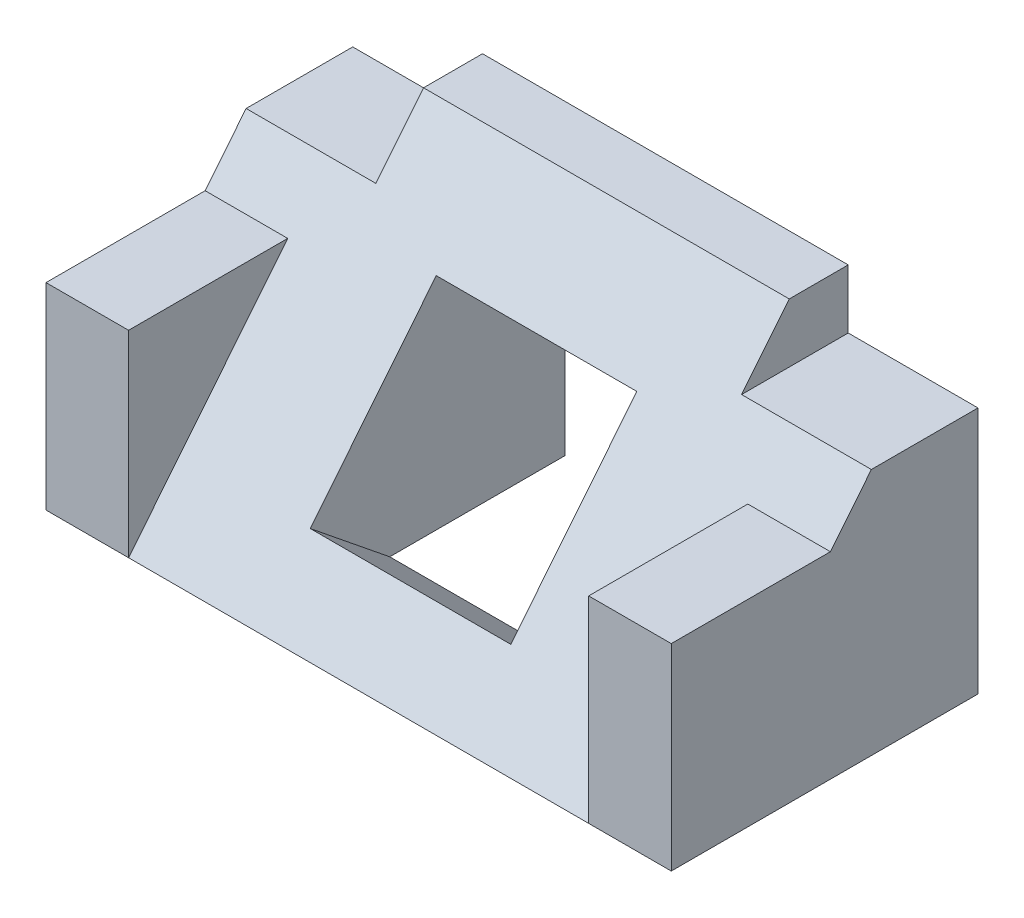
from build123d import *

# Parameters (mm, degrees)
SKETCH2_W               = 26
SKETCH2_H               = 26
BOSS_EXTRUDE1_DEPTH     = 53
CUT_EXTRUDE2_DEPTH      = 1
CUT_EXTRUDE2_DEPTH_BACK = 54
SKETCH4_W               = 11
SKETCH4_H               = 5
CUT_EXTRUDE3_DEPTH      = 27
SKETCH5_W               = 17
SKETCH5_H               = 17
CUT_EXTRUDE4_DEPTH      = 21.226470685
BOSS_EXTRUDE3_DEPTH     = 7
BOSS_EXTRUDE4_DEPTH     = 7


with BuildPart() as part:
    # Sketch2 → Boss-Extrude1 (new body)
    with BuildSketch(Plane(origin=(0, 0, 0), x_dir=(0, 0, -1), z_dir=(1, 0, 0))):
        with Locations((13, 13)):
            Rectangle(SKETCH2_W, SKETCH2_H)
    extrude(amount=BOSS_EXTRUDE1_DEPTH)

    # Sketch3 → Cut-Extrude2 (cut, two sides)
    with BuildSketch(Plane(origin=(53, 0, 0), x_dir=(0, 0, -1), z_dir=(1, 0, 0))) as cut_extrude2_sk:
        Polygon((-52.490719717, -64.988510126), (0, 0), (21, 26), (73.490719717, 90.988510126), (-56.486300535, 195.969949561), (-182.46773997, 39.992929308), align=None)
    extrude(amount=CUT_EXTRUDE2_DEPTH, mode=Mode.SUBTRACT)
    extrude(cut_extrude2_sk.sketch, amount=-CUT_EXTRUDE2_DEPTH_BACK, mode=Mode.SUBTRACT)

    # Sketch4 → Cut-Extrude3 (cut, through all)
    with BuildSketch(Plane(origin=(0, 0, -26), x_dir=(-1, 0, 0), z_dir=(0, 0, -1))):
        with Locations((-5.5, 23.5)):
            Rectangle(SKETCH4_W, SKETCH4_H)
        with Locations((-47.5, 23.5)):
            Rectangle(SKETCH4_W, SKETCH4_H)
    extrude(amount=-CUT_EXTRUDE3_DEPTH, mode=Mode.SUBTRACT)

    # Sketch5 → Cut-Extrude4 (cut, through all)
    with BuildSketch(Plane(origin=(0, 0, 0), x_dir=(1, 0, 0), z_dir=(0, 0.628337107, 0.77794118))):
        with Locations((26.5, 15.5)):
            Rectangle(SKETCH5_W, SKETCH5_H)
    extrude(amount=-CUT_EXTRUDE4_DEPTH, mode=Mode.SUBTRACT)

    # Sketch6 → Boss-Extrude3 (add)
    with BuildSketch(Plane(origin=(53, 0, 0), x_dir=(0, 0, -1), z_dir=(1, 0, 0))):
        Polygon((0, 0), (0, 16.7), (13.488461538, 16.7), align=None)
    extrude(amount=-BOSS_EXTRUDE3_DEPTH)

    # Sketch8 → Boss-Extrude4 (add)
    with BuildSketch(Plane.ZY):
        Polygon((0, 0), (0, 16.7), (-13.488461538, 16.7), align=None)
    extrude(amount=-BOSS_EXTRUDE4_DEPTH)


solid = part.part
